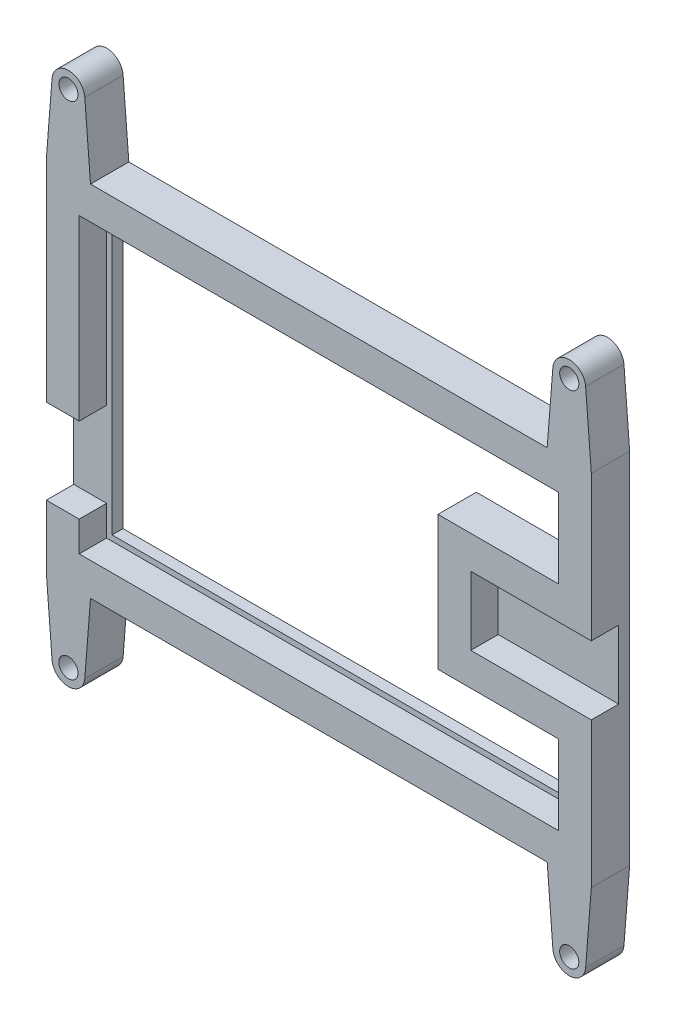
from build123d import *

# Parameters (mm, degrees)
BOSS_EXTRUDE1_DEPTH   = 5
SHELL1_T              = 6
SKETCH4_W             = 99.5
SKETCH4_H             = 65.5
BOSS_EXTRUDE2_DEPTH   = 2
SKETCH5_W             = 6
SKETCH5_H             = 15.5
CUT_EXTRUDE2_DEPTH    = 5
SKETCH7_R             = 3
SKETCH7_R_2           = 1.75
BOSS_EXTRUDE3_DEPTH   = 7
BOSS_EXTRUDE3_2_DEPTH = 7
BOSS_EXTRUDE3_3_DEPTH = 7
BOSS_EXTRUDE3_4_DEPTH = 7
BOSS_EXTRUDE4_DEPTH   = 7


with BuildPart() as part:
    # Sketch1 → Boss-Extrude1 (new body)
    with BuildSketch(Plane.XY):
        Polygon((43.75, 26.75), (-43.75, 26.75), (-43.75, -26.75), (43.75, -26.75), (43.75, -12.25), (21.75, -12.25), (21.75, 12.25), (43.75, 12.25), align=None)
    extrude(amount=BOSS_EXTRUDE1_DEPTH)

    # Shell1
    shell1_openings = [part.faces().sort_by_distance(p)[0] for p in [
        (-4.261512463, 0, 0),
        (-4.261512463, 0, 5),
    ]]
    offset(amount=SHELL1_T, openings=shell1_openings, kind=Kind.INTERSECTION)

    # Sketch4 → Boss-Extrude2 (add)
    with BuildSketch(Plane(origin=(0, 0, 0), x_dir=(-1, 0, 0), z_dir=(0, 0, -1))):
        Rectangle(SKETCH4_W, SKETCH4_H)
        Polygon((-42.75, 12.25), (-42.75, 25.75), (42.75, 25.75), (42.75, -25.75), (-42.75, -25.75), (-42.75, -12.25), (-21.75, -12.25), (-21.75, 12.25), align=None, mode=Mode.SUBTRACT)
    extrude(amount=BOSS_EXTRUDE2_DEPTH)

    # Sketch5 → Cut-Extrude2 (cut)
    with BuildSketch(Plane.XY.offset(5)):
        with Locations((-46.75, -13.5)):
            Rectangle(SKETCH5_W, SKETCH5_H)
    extrude(amount=-CUT_EXTRUDE2_DEPTH, mode=Mode.SUBTRACT)



with BuildPart() as body_2:
    # Sketch7 → Boss-Extrude3 (new body)
    with BuildSketch(Plane(origin=(0, 0, -2), x_dir=(-1, 0, 0), z_dir=(0, 0, -1))):
        with Locations((-45.72, 45.72)):
            Circle(SKETCH7_R)
        with Locations((-45.72, 45.72)):
            Circle(SKETCH7_R_2, mode=Mode.SUBTRACT)
    extrude(amount=-BOSS_EXTRUDE3_DEPTH)


with BuildPart() as body_3:
    # Sketch7 → Boss-Extrude3 2 (new body)
    with BuildSketch(Plane(origin=(0, 0, -2), x_dir=(-1, 0, 0), z_dir=(0, 0, -1))):
        with Locations((45.72, 45.72)):
            Circle(SKETCH7_R)
        with Locations((45.72, 45.72)):
            Circle(SKETCH7_R_2, mode=Mode.SUBTRACT)
    extrude(amount=-BOSS_EXTRUDE3_2_DEPTH)


with BuildPart() as body_4:
    # Sketch7 → Boss-Extrude3 3 (new body)
    with BuildSketch(Plane(origin=(0, 0, -2), x_dir=(-1, 0, 0), z_dir=(0, 0, -1))):
        with Locations((45.72, -45.72)):
            Circle(SKETCH7_R)
        with Locations((45.72, -45.72)):
            Circle(SKETCH7_R_2, mode=Mode.SUBTRACT)
    extrude(amount=-BOSS_EXTRUDE3_3_DEPTH)


with BuildPart() as body_5:
    # Sketch7 → Boss-Extrude3 4 (new body)
    with BuildSketch(Plane(origin=(0, 0, -2), x_dir=(-1, 0, 0), z_dir=(0, 0, -1))):
        with Locations((-45.72, -45.72)):
            Circle(SKETCH7_R)
        with Locations((-45.72, -45.72)):
            Circle(SKETCH7_R_2, mode=Mode.SUBTRACT)
    extrude(amount=-BOSS_EXTRUDE3_4_DEPTH)


with BuildPart() as part_1:
    add(part.part)

    add(body_2.part)  # Boss-Extrude4 merges body 2

    add(body_3.part)  # Boss-Extrude4 merges body 3

    add(body_4.part)  # Boss-Extrude4 merges body 4

    add(body_5.part)  # Boss-Extrude4 merges body 5
    # Sketch8 → Boss-Extrude4 (add)
    with BuildSketch(Plane(origin=(0, 0, -2), x_dir=(-1, 0, 0), z_dir=(0, 0, -1))):
        with BuildLine():
            Line((-48.71075267, 45.955368794), (-49.75, 32.75))
            Line((-49.75, 32.75), (-41.69, 32.75))
            Line((-41.69, 32.75), (-42.72924733, 45.955368794))
            ThreePointArc((-42.72924733, 45.955368794), (-42.722312724, 45.837775191), (-42.72, 45.72))
            ThreePointArc((-42.72, 45.72), (-45.837775191, 42.722312724), (-48.71075267, 45.955368794))
        make_face()
        with BuildLine():
            Line((42.72924733, 45.955368794), (41.69, 32.75))
            Line((41.69, 32.75), (49.75, 32.75))
            Line((49.75, 32.75), (48.71075267, 45.955368794))
            ThreePointArc((48.71075267, 45.955368794), (48.717687276, 45.837775191), (48.72, 45.72))
            ThreePointArc((48.72, 45.72), (45.602224809, 42.722312724), (42.72924733, 45.955368794))
        make_face()
        with BuildLine():
            Line((49.75, -32.75), (41.69, -32.75))
            Line((41.69, -32.75), (42.72924733, -45.955368794))
            ThreePointArc((42.72924733, -45.955368794), (45.602224809, -42.722312724), (48.72, -45.72))
            ThreePointArc((48.72, -45.72), (48.717687276, -45.837775191), (48.71075267, -45.955368794))
            Line((48.71075267, -45.955368794), (49.75, -32.75))
        make_face()
        with BuildLine():
            Line((-42.72924733, -45.955368794), (-41.69, -32.75))
            Line((-41.69, -32.75), (-49.75, -32.75))
            Line((-49.75, -32.75), (-48.71075267, -45.955368794))
            ThreePointArc((-48.71075267, -45.955368794), (-45.837775191, -42.722312724), (-42.72, -45.72))
            ThreePointArc((-42.72, -45.72), (-42.722312724, -45.837775191), (-42.72924733, -45.955368794))
        make_face()
    extrude(amount=-BOSS_EXTRUDE4_DEPTH)


solid = part_1.part
